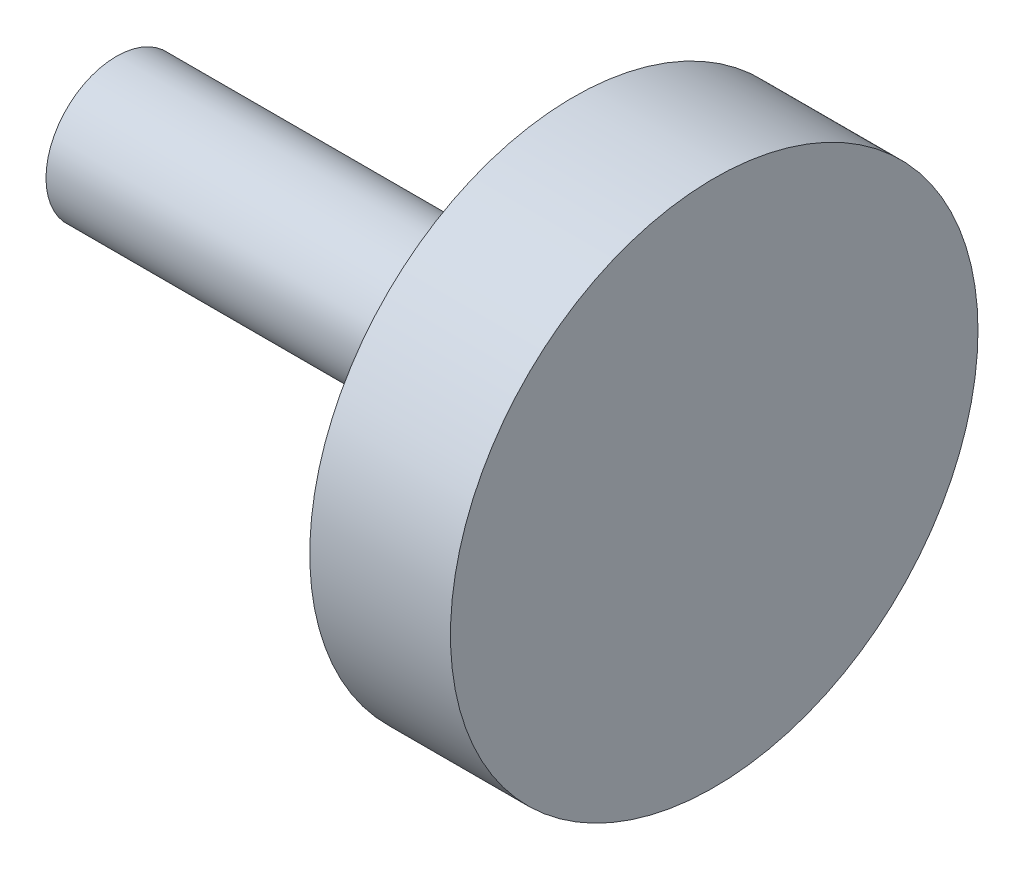
from build123d import *

# Parameters (mm, degrees)
SKETCH1_R           = 7.5
BOSS_EXTRUDE1_DEPTH = 4
SKETCH2_R           = 2
BOSS_EXTRUDE3_DEPTH = 13


with BuildPart() as part:
    # Sketch1 → Boss-Extrude1 (new body)
    with BuildSketch(Plane(origin=(0, 0, 0), x_dir=(0, 0, -1), z_dir=(1, 0, 0))):
        Circle(SKETCH1_R)
    extrude(amount=BOSS_EXTRUDE1_DEPTH)

    # Sketch2 → Boss-Extrude3 (add)
    with BuildSketch(Plane.ZY):
        Circle(SKETCH2_R)
    extrude(amount=BOSS_EXTRUDE3_DEPTH)


solid = part.part
